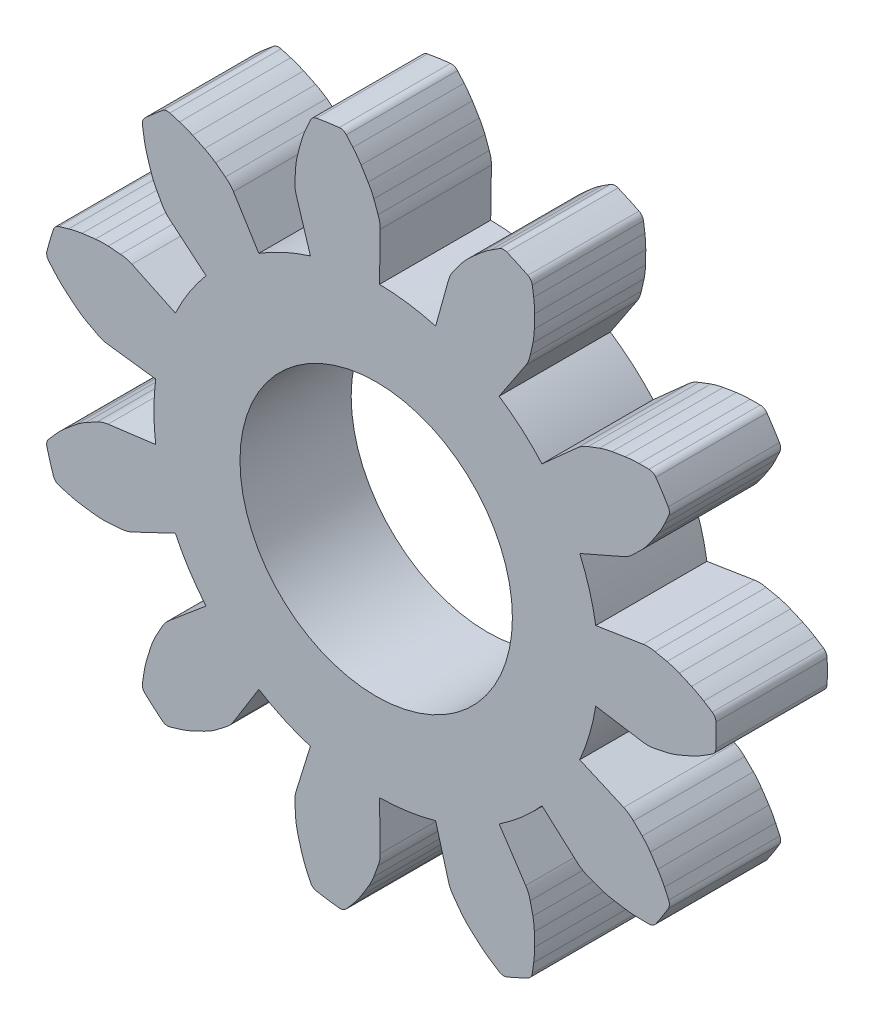
from build123d import *

# Parameters (mm, degrees)
BOSS_EXTRUDE1_DEPTH = 2
SKETCH2_R           = 2.45
CUT_EXTRUDE1_DEPTH  = 2


with BuildPart() as part:
    # Model → Boss-Extrude1 (new body)
    with BuildSketch(Plane.XY):
        with BuildLine():
            Line((12.717474525, 8.359321698), (13.570645119, 8.494996797))
            ThreePointArc((13.570645119, 8.494996797), (13.677360097, 8.501294244), (13.783236646, 8.486532792))
            ThreePointArc((13.783236646, 8.486532792), (13.891944703, 8.463851968), (14.000649175, 8.441153964))
            ThreePointArc((14.000649175, 8.441153964), (14.111872173, 8.409461779), (14.220209346, 8.368989483))
            ThreePointArc((14.220209346, 8.368989483), (14.330605558, 8.321811935), (14.440350312, 8.273138193))
            ThreePointArc((14.440350312, 8.273138193), (14.552066881, 8.217929414), (14.659736482, 8.155192999))
            ThreePointArc((14.659736482, 8.155192999), (14.736291079, 8.106775511), (14.812576461, 8.057934955))
            ThreePointArc((14.812576461, 8.057934955), (14.861069615, 8.006646229), (14.880241201, 7.938715604))
            ThreePointArc((14.880241201, 7.938715604), (14.882877492, 7.83507664), (14.88375634, 7.731407877))
            ThreePointArc((14.88375634, 7.731407877), (14.882877492, 7.627739113), (14.880241201, 7.524100149))
            ThreePointArc((14.880241201, 7.524100149), (14.861069615, 7.456169524), (14.812576461, 7.404880798))
            ThreePointArc((14.812576461, 7.404880798), (14.736291079, 7.356040242), (14.659736482, 7.307622754))
            ThreePointArc((14.659736482, 7.307622754), (14.552066881, 7.244886339), (14.440350312, 7.18967756))
            ThreePointArc((14.440350312, 7.18967756), (14.330605558, 7.141003818), (14.220209346, 7.09382627))
            ThreePointArc((14.220209346, 7.09382627), (14.111872173, 7.053353974), (14.000649175, 7.021661789))
            ThreePointArc((14.000649175, 7.021661789), (13.891944703, 6.998963785), (13.783236646, 6.976282961))
            ThreePointArc((13.783236646, 6.976282961), (13.677360097, 6.961521509), (13.570645119, 6.967818956))
            Line((13.570645119, 6.967818956), (12.717474525, 7.103494055))
            ThreePointArc((12.717474525, 7.103494055), (12.669277659, 6.852450167), (12.605136581, 6.604999376))
            ThreePointArc((12.605136581, 6.604999376), (12.525313492, 6.362153239), (12.430134702, 6.124904488))
            Line((12.430134702, 6.124904488), (13.221218975, 5.777782798))
            ThreePointArc((13.221218975, 5.777782798), (13.314397984, 5.725386074), (13.395486362, 5.655726766))
            ThreePointArc((13.395486362, 5.655726766), (13.47467522, 5.57787443), (13.553851773, 5.50000958))
            ThreePointArc((13.553851773, 5.50000958), (13.630284425, 5.413216725), (13.699542479, 5.320597764))
            ThreePointArc((13.699542479, 5.320597764), (13.766907574, 5.221224788), (13.832915725, 5.120945336))
            ThreePointArc((13.832915725, 5.120945336), (13.897049563, 5.014102219), (13.953709129, 4.903114407))
            ThreePointArc((13.953709129, 4.903114407), (13.991934483, 4.820994484), (14.029704632, 4.738664203))
            ThreePointArc((14.029704632, 4.738664203), (14.042770891, 4.669300002), (14.022172987, 4.601788183))
            ThreePointArc((14.022172987, 4.601788183), (13.968359322, 4.513176251), (13.913051091, 4.425489396))
            ThreePointArc((13.913051091, 4.425489396), (13.856264192, 4.338752824), (13.798014948, 4.252991466))
            ThreePointArc((13.798014948, 4.252991466), (13.745160716, 4.20620953), (13.676636899, 4.189280087))
            ThreePointArc((13.676636899, 4.189280087), (13.586056354, 4.189435788), (13.495478059, 4.190092944))
            ThreePointArc((13.495478059, 4.190092944), (13.370982759, 4.195526295), (13.247152683, 4.209480251))
            ThreePointArc((13.247152683, 4.209480251), (13.128514508, 4.227865787), (13.010137197, 4.247862207))
            ThreePointArc((13.010137197, 4.247862207), (12.897117192, 4.272386242), (12.786416363, 4.305856772))
            ThreePointArc((12.786416363, 4.305856772), (12.682696876, 4.345532071), (12.578983659, 4.38522376))
            ThreePointArc((12.578983659, 4.38522376), (12.481933994, 4.430046821), (12.395564299, 4.493039043))
            Line((12.395564299, 4.493039043), (11.751183019, 5.068435048))
            ThreePointArc((11.751183019, 5.068435048), (11.574912663, 4.883300682), (11.387171756, 4.709809115))
            ThreePointArc((11.387171756, 4.709809115), (11.188727766, 4.548669565), (10.980391915, 4.400540754))
            Line((10.980391915, 4.400540754), (11.4582262, 3.680830957))
            ThreePointArc((11.4582262, 3.680830957), (11.508285563, 3.586375653), (11.538840782, 3.483934827))
            ThreePointArc((11.538840782, 3.483934827), (11.563368537, 3.375628545), (11.587879177, 3.267318388))
            ThreePointArc((11.587879177, 3.267318388), (11.605254654, 3.152980981), (11.613444647, 3.037621223))
            ThreePointArc((11.613444647, 3.037621223), (11.616390684, 2.917603035), (11.617705109, 2.797555891))
            ThreePointArc((11.617705109, 2.797555891), (11.613894177, 2.673000371), (11.601554695, 2.548999008))
            ThreePointArc((11.601554695, 2.548999008), (11.589314528, 2.459249146), (11.576577688, 2.369568422))
            ThreePointArc((11.576577688, 2.369568422), (11.550068607, 2.30415139), (11.496240902, 2.258492901))
            ThreePointArc((11.496240902, 2.258492901), (11.403062739, 2.213041664), (11.309127401, 2.169176675))
            ThreePointArc((11.309127401, 2.169176675), (11.21446189, 2.126910543), (11.119093417, 2.086255416))
            ThreePointArc((11.119093417, 2.086255416), (11.049337383, 2.075475102), (10.982538733, 2.098279921))
            ThreePointArc((10.982538733, 2.098279921), (10.906421707, 2.147382445), (10.830577682, 2.196905604))
            ThreePointArc((10.830577682, 2.196905604), (10.728783063, 2.268783669), (10.632154652, 2.347470079))
            ThreePointArc((10.632154652, 2.347470079), (10.542289839, 2.427077616), (10.453515389, 2.50789928))
            ThreePointArc((10.453515389, 2.50789928), (10.371695605, 2.589633439), (10.296663677, 2.677640028))
            ThreePointArc((10.296663677, 2.677640028), (10.230859377, 2.767092002), (10.165069214, 2.856554373))
            ThreePointArc((10.165069214, 2.856554373), (10.107659017, 2.946730942), (10.069056373, 3.046418354))
            Line((10.069056373, 3.046418354), (9.838050911, 3.878851097))
            ThreePointArc((9.838050911, 3.878851097), (9.589671656, 3.818405108), (9.337937332, 3.773955112))
            ThreePointArc((9.337937332, 3.773955112), (9.083877007, 3.745682816), (8.828529254, 3.733703796))
            Line((8.828529254, 3.733703796), (8.841404541, 2.869908668))
            ThreePointArc((8.841404541, 2.869908668), (8.832450765, 2.763383675), (8.802771759, 2.660685569))
            ThreePointArc((8.802771759, 2.660685569), (8.764851023, 2.556311822), (8.726913793, 2.451944068))
            ThreePointArc((8.726913793, 2.451944068), (8.679715506, 2.346363427), (8.624237172, 2.244888779))
            ThreePointArc((8.624237172, 2.244888779), (8.561828805, 2.142330307), (8.498032184, 2.040629591))
            ThreePointArc((8.498032184, 2.040629591), (8.427486425, 1.937907165), (8.350065594, 1.840261808))
            ThreePointArc((8.350065594, 1.840261808), (8.291246072, 1.771376953), (8.2320461, 1.702818782))
            ThreePointArc((8.2320461, 1.702818782), (8.174378124, 1.662118365), (8.104410534, 1.652809454))
            ThreePointArc((8.104410534, 1.652809454), (8.001451282, 1.664949359), (7.898712644, 1.67883306))
            ThreePointArc((7.898712644, 1.67883306), (7.796224152, 1.694456566), (7.694015266, 1.711815386))
            ThreePointArc((7.694015266, 1.711815386), (7.629504479, 1.740459368), (7.585639093, 1.795758079))
            ThreePointArc((7.585639093, 1.795758079), (7.548152206, 1.878217722), (7.511122393, 1.96088363))
            ThreePointArc((7.511122393, 1.96088363), (7.464347526, 2.076385633), (7.425599618, 2.194822116))
            ThreePointArc((7.425599618, 2.194822116), (7.393039611, 2.310376823), (7.362053282, 2.426363425))
            ThreePointArc((7.362053282, 2.426363425), (7.337410922, 2.53935769), (7.321870001, 2.653958867))
            ThreePointArc((7.321870001, 2.653958867), (7.31487329, 2.764787146), (7.307894093, 2.87561653))
            ThreePointArc((7.307894093, 2.87561653), (7.308350696, 2.982516183), (7.329771168, 3.087248736))
            Line((7.329771168, 3.087248736), (7.585484126, 3.912426704))
            ThreePointArc((7.585484126, 3.912426704), (7.343854632, 3.995860265), (7.10805076, 4.094564399))
            ThreePointArc((7.10805076, 4.094564399), (6.879036457, 4.208135612), (6.65774791, 4.336109637))
            Line((6.65774791, 4.336109637), (6.201576387, 3.602478028))
            ThreePointArc((6.201576387, 3.602478028), (6.136452232, 3.517704279), (6.055961876, 3.447354816))
            ThreePointArc((6.055961876, 3.447354816), (5.967632214, 3.38005153), (5.879291918, 3.312762203))
            ThreePointArc((5.879291918, 3.312762203), (5.782504988, 3.249459437), (5.680972307, 3.194087382))
            ThreePointArc((5.680972307, 3.194087382), (5.573023751, 3.141550216), (5.46437106, 3.090485187))
            ThreePointArc((5.46437106, 3.090485187), (5.349488255, 3.0422095), (5.231566642, 3.001921859))
            ThreePointArc((5.231566642, 3.001921859), (5.144842547, 2.975772467), (5.057975016, 2.950103585))
            ThreePointArc((5.057975016, 2.950103585), (4.987457321, 2.947041876), (4.923564061, 2.977038057))
            ThreePointArc((4.923564061, 2.977038057), (4.843512555, 3.042914769), (4.764589408, 3.110139183))
            ThreePointArc((4.764589408, 3.110139183), (4.686817307, 3.178691975), (4.610218607, 3.248553439))
            ThreePointArc((4.610218607, 3.248553439), (4.571434785, 3.307527455), (4.564429615, 3.377763109))
            ThreePointArc((4.564429615, 3.377763109), (4.577474687, 3.467399516), (4.591015791, 3.556962332))
            ThreePointArc((4.591015791, 3.556962332), (4.614111366, 3.679417202), (4.645546148, 3.800001012))
            ThreePointArc((4.645546148, 3.800001012), (4.680628519, 3.914815087), (4.717268251, 4.0291417))
            ThreePointArc((4.717268251, 4.0291417), (4.757627091, 4.13752119), (4.80651131, 4.242331891))
            ThreePointArc((4.80651131, 4.242331891), (4.860543594, 4.33934928), (4.914591208, 4.43635813))
            ThreePointArc((4.914591208, 4.43635813), (4.972769642, 4.526040982), (5.047412384, 4.60256683))
            Line((5.047412384, 4.60256683), (5.708656704, 5.158501849))
            ThreePointArc((5.708656704, 5.158501849), (5.550492627, 5.359325394), (5.405485271, 5.569845793))
            ThreePointArc((5.405485271, 5.569845793), (5.274227413, 5.789202458), (5.157255622, 6.016498679))
            Line((5.157255622, 6.016498679), (4.376868525, 5.645953442))
            ThreePointArc((4.376868525, 5.645953442), (4.276250449, 5.609846002), (4.170503862, 5.59418064))
            ThreePointArc((4.170503862, 5.59418064), (4.059809318, 5.585316134), (3.949113375, 5.576469119))
            ThreePointArc((3.949113375, 5.576469119), (3.83346697, 5.575542408), (3.71811585, 5.583853184))
            ThreePointArc((3.71811585, 5.583853184), (3.59890001, 5.598017502), (3.479887711, 5.613800946))
            ThreePointArc((3.479887711, 5.613800946), (3.357142338, 5.635299187), (3.236159221, 5.665160304))
            ThreePointArc((3.236159221, 5.665160304), (3.149064841, 5.690048622), (3.062109578, 5.715418716))
            ThreePointArc((3.062109578, 5.715418716), (3.001131033, 5.750967788), (2.963597763, 5.810745485))
            ThreePointArc((2.963597763, 5.810745485), (2.93186979, 5.909443614), (2.901819675, 6.008665464))
            ThreePointArc((2.901819675, 6.008665464), (2.873456058, 6.108382515), (2.846787091, 6.208566102))
            ThreePointArc((2.846787091, 6.208566102), (2.846043824, 6.279146318), (2.878122961, 6.342019591))
            ThreePointArc((2.878122961, 6.342019591), (2.937558274, 6.410373837), (2.997371089, 6.478397999))
            ThreePointArc((2.997371089, 6.478397999), (3.083004425, 6.56892718), (3.174641576, 6.65337381))
            ThreePointArc((3.174641576, 6.65337381), (3.26622792, 6.730994594), (3.358860857, 6.807363327))
            ThreePointArc((3.358860857, 6.807363327), (3.45140725, 6.87671832), (3.549196215, 6.938461888))
            ThreePointArc((3.549196215, 6.938461888), (3.647102625, 6.990866051), (3.745017316, 7.043254742))
            ThreePointArc((3.745017316, 7.043254742), (3.84244634, 7.087247123), (3.946612807, 7.11126985))
            Line((3.946612807, 7.11126985), (4.80344809, 7.221456478))
            ThreePointArc((4.80344809, 7.221456478), (4.778965407, 7.475909951), (4.770793377, 7.731407877))
            ThreePointArc((4.770793377, 7.731407877), (4.778965407, 7.986905802), (4.80344809, 8.241359275))
            Line((4.80344809, 8.241359275), (3.946612807, 8.351545903))
            ThreePointArc((3.946612807, 8.351545903), (3.84244634, 8.37556863), (3.745017316, 8.419561011))
            ThreePointArc((3.745017316, 8.419561011), (3.647102625, 8.471949702), (3.549196215, 8.524353865))
            ThreePointArc((3.549196215, 8.524353865), (3.45140725, 8.586097433), (3.358860857, 8.655452426))
            ThreePointArc((3.358860857, 8.655452426), (3.26622792, 8.731821159), (3.174641576, 8.809441943))
            ThreePointArc((3.174641576, 8.809441943), (3.083004425, 8.893888573), (2.997371089, 8.984417754))
            ThreePointArc((2.997371089, 8.984417754), (2.937558274, 9.052441916), (2.878122961, 9.120796162))
            ThreePointArc((2.878122961, 9.120796162), (2.846043824, 9.183669435), (2.846787091, 9.254249651))
            ThreePointArc((2.846787091, 9.254249651), (2.873456058, 9.354433239), (2.901819675, 9.454150289))
            ThreePointArc((2.901819675, 9.454150289), (2.93186979, 9.553372139), (2.963597763, 9.652070268))
            ThreePointArc((2.963597763, 9.652070268), (3.001131033, 9.711847965), (3.062109578, 9.747397037))
            ThreePointArc((3.062109578, 9.747397037), (3.149064841, 9.772767131), (3.236159221, 9.797655449))
            ThreePointArc((3.236159221, 9.797655449), (3.357142338, 9.827516566), (3.479887711, 9.849014807))
            ThreePointArc((3.479887711, 9.849014807), (3.59890001, 9.864798251), (3.71811585, 9.878962569))
            ThreePointArc((3.71811585, 9.878962569), (3.83346697, 9.887273345), (3.949113375, 9.886346634))
            ThreePointArc((3.949113375, 9.886346634), (4.059809318, 9.87749962), (4.170503862, 9.868635113))
            ThreePointArc((4.170503862, 9.868635113), (4.276250449, 9.852969751), (4.376868525, 9.816862311))
            Line((4.376868525, 9.816862311), (5.157255622, 9.446317074))
            ThreePointArc((5.157255622, 9.446317074), (5.274227413, 9.673613295), (5.405485271, 9.89296996))
            ThreePointArc((5.405485271, 9.89296996), (5.550492627, 10.103490359), (5.708656704, 10.304313904))
            Line((5.708656704, 10.304313904), (5.047412384, 10.860248923))
            ThreePointArc((5.047412384, 10.860248923), (4.972769642, 10.936774771), (4.914591208, 11.026457624))
            ThreePointArc((4.914591208, 11.026457624), (4.860543594, 11.123466473), (4.80651131, 11.220483862))
            ThreePointArc((4.80651131, 11.220483862), (4.757627091, 11.325294563), (4.717268251, 11.433674053))
            ThreePointArc((4.717268251, 11.433674053), (4.680628519, 11.548000666), (4.645546148, 11.662814741))
            ThreePointArc((4.645546148, 11.662814741), (4.614111366, 11.783398551), (4.591015791, 11.905853421))
            ThreePointArc((4.591015791, 11.905853421), (4.577474687, 11.995416237), (4.564429615, 12.085052644))
            ThreePointArc((4.564429615, 12.085052644), (4.571434785, 12.155288298), (4.610218607, 12.214262314))
            ThreePointArc((4.610218607, 12.214262314), (4.686817307, 12.284123778), (4.764589408, 12.35267657))
            ThreePointArc((4.764589408, 12.35267657), (4.843512555, 12.419900984), (4.923564061, 12.485777696))
            ThreePointArc((4.923564061, 12.485777696), (4.987457321, 12.515773877), (5.057975016, 12.512712169))
            ThreePointArc((5.057975016, 12.512712169), (5.144842547, 12.487043286), (5.231566642, 12.460893894))
            ThreePointArc((5.231566642, 12.460893894), (5.349488255, 12.420606253), (5.46437106, 12.372330566))
            ThreePointArc((5.46437106, 12.372330566), (5.573023751, 12.321265537), (5.680972307, 12.268728371))
            ThreePointArc((5.680972307, 12.268728371), (5.782504988, 12.213356316), (5.879291918, 12.15005355))
            ThreePointArc((5.879291918, 12.15005355), (5.967632214, 12.082764223), (6.055961876, 12.015460937))
            ThreePointArc((6.055961876, 12.015460937), (6.136452232, 11.945111474), (6.201576387, 11.860337725))
            Line((6.201576387, 11.860337725), (6.65774791, 11.126706116))
            ThreePointArc((6.65774791, 11.126706116), (6.879036457, 11.254680141), (7.10805076, 11.368251354))
            ThreePointArc((7.10805076, 11.368251354), (7.343854632, 11.466955488), (7.585484126, 11.550389049))
            Line((7.585484126, 11.550389049), (7.329771168, 12.375567018))
            ThreePointArc((7.329771168, 12.375567018), (7.308350696, 12.48029957), (7.307894093, 12.587199223))
            ThreePointArc((7.307894093, 12.587199223), (7.31487329, 12.698028607), (7.321870001, 12.808856886))
            ThreePointArc((7.321870001, 12.808856886), (7.337410922, 12.923458063), (7.362053282, 13.036452328))
            ThreePointArc((7.362053282, 13.036452328), (7.393039611, 13.15243893), (7.425599618, 13.267993637))
            ThreePointArc((7.425599618, 13.267993637), (7.464347526, 13.38643012), (7.511122393, 13.501932123))
            ThreePointArc((7.511122393, 13.501932123), (7.548152206, 13.584598031), (7.585639093, 13.667057674))
            ThreePointArc((7.585639093, 13.667057674), (7.629504479, 13.722356385), (7.694015266, 13.751000367))
            ThreePointArc((7.694015266, 13.751000367), (7.796224152, 13.768359187), (7.898712644, 13.783982693))
            ThreePointArc((7.898712644, 13.783982693), (8.001451282, 13.797866394), (8.104410534, 13.810006299))
            ThreePointArc((8.104410534, 13.810006299), (8.174378124, 13.800697388), (8.2320461, 13.759996971))
            ThreePointArc((8.2320461, 13.759996971), (8.291246072, 13.6914388), (8.350065594, 13.622553946))
            ThreePointArc((8.350065594, 13.622553946), (8.427486425, 13.524908588), (8.498032184, 13.422186162))
            ThreePointArc((8.498032184, 13.422186162), (8.561828805, 13.320485446), (8.624237172, 13.217926975))
            ThreePointArc((8.624237172, 13.217926975), (8.679715506, 13.116452326), (8.726913793, 13.010871686))
            ThreePointArc((8.726913793, 13.010871686), (8.764851023, 12.906503932), (8.802771759, 12.802130184))
            ThreePointArc((8.802771759, 12.802130184), (8.832450765, 12.699432078), (8.841404541, 12.592907085))
            Line((8.841404541, 12.592907085), (8.828529254, 11.729111957))
            ThreePointArc((8.828529254, 11.729111957), (9.083877007, 11.717132937), (9.337937332, 11.688860641))
            ThreePointArc((9.337937332, 11.688860641), (9.589671656, 11.644410645), (9.838050911, 11.583964656))
            Line((9.838050911, 11.583964656), (10.069056373, 12.416397399))
            ThreePointArc((10.069056373, 12.416397399), (10.107659017, 12.516084811), (10.165069214, 12.60626138))
            ThreePointArc((10.165069214, 12.60626138), (10.230859377, 12.695723751), (10.296663677, 12.785175725))
            ThreePointArc((10.296663677, 12.785175725), (10.371695605, 12.873182314), (10.453515389, 12.954916473))
            ThreePointArc((10.453515389, 12.954916473), (10.542289839, 13.035738137), (10.632154652, 13.115345674))
            ThreePointArc((10.632154652, 13.115345674), (10.728783063, 13.194032084), (10.830577682, 13.265910149))
            ThreePointArc((10.830577682, 13.265910149), (10.906421707, 13.315433308), (10.982538733, 13.364535832))
            ThreePointArc((10.982538733, 13.364535832), (11.049337383, 13.387340651), (11.119093417, 13.376560337))
            ThreePointArc((11.119093417, 13.376560337), (11.21446189, 13.33590521), (11.309127401, 13.293639078))
            ThreePointArc((11.309127401, 13.293639078), (11.403062739, 13.249774089), (11.496240902, 13.204322852))
            ThreePointArc((11.496240902, 13.204322852), (11.550068607, 13.158664363), (11.576577688, 13.093247332))
            ThreePointArc((11.576577688, 13.093247332), (11.589314528, 13.003566607), (11.601554695, 12.913816745))
            ThreePointArc((11.601554695, 12.913816745), (11.613894177, 12.789815382), (11.617705109, 12.665259862))
            ThreePointArc((11.617705109, 12.665259862), (11.616390684, 12.545212718), (11.613444647, 12.425194531))
            ThreePointArc((11.613444647, 12.425194531), (11.605254654, 12.309834772), (11.587879177, 12.195497365))
            ThreePointArc((11.587879177, 12.195497365), (11.563368537, 12.087187208), (11.538840782, 11.978880926))
            ThreePointArc((11.538840782, 11.978880926), (11.508285563, 11.8764401), (11.4582262, 11.781984796))
            Line((11.4582262, 11.781984796), (10.980391915, 11.062274999))
            ThreePointArc((10.980391915, 11.062274999), (11.188727766, 10.914146188), (11.387171756, 10.753006638))
            ThreePointArc((11.387171756, 10.753006638), (11.574912663, 10.579515071), (11.751183019, 10.394380705))
            Line((11.751183019, 10.394380705), (12.395564299, 10.96977671))
            ThreePointArc((12.395564299, 10.96977671), (12.481933994, 11.032768932), (12.578983659, 11.077591993))
            ThreePointArc((12.578983659, 11.077591993), (12.682696876, 11.117283682), (12.786416363, 11.156958981))
            ThreePointArc((12.786416363, 11.156958981), (12.897117192, 11.190429511), (13.010137197, 11.214953546))
            ThreePointArc((13.010137197, 11.214953546), (13.128514508, 11.234949966), (13.247152683, 11.253335502))
            ThreePointArc((13.247152683, 11.253335502), (13.370982759, 11.267289458), (13.495478059, 11.272722809))
            ThreePointArc((13.495478059, 11.272722809), (13.586056354, 11.273379965), (13.676636899, 11.273535666))
            ThreePointArc((13.676636899, 11.273535666), (13.745160716, 11.256606223), (13.798014948, 11.209824287))
            ThreePointArc((13.798014948, 11.209824287), (13.856264192, 11.124062929), (13.913051091, 11.037326357))
            ThreePointArc((13.913051091, 11.037326357), (13.968359322, 10.949639502), (14.022172987, 10.86102757))
            ThreePointArc((14.022172987, 10.86102757), (14.042770891, 10.793515751), (14.029704632, 10.72415155))
            ThreePointArc((14.029704632, 10.72415155), (13.991934483, 10.641821269), (13.953709129, 10.559701346))
            ThreePointArc((13.953709129, 10.559701346), (13.897049563, 10.448713534), (13.832915725, 10.341870417))
            ThreePointArc((13.832915725, 10.341870417), (13.766907574, 10.241590965), (13.699542479, 10.142217989))
            ThreePointArc((13.699542479, 10.142217989), (13.630284425, 10.049599028), (13.553851773, 9.962806173))
            ThreePointArc((13.553851773, 9.962806173), (13.47467522, 9.884941323), (13.395486362, 9.807088987))
            ThreePointArc((13.395486362, 9.807088987), (13.314397984, 9.737429679), (13.221218975, 9.685032956))
            Line((13.221218975, 9.685032956), (12.430134702, 9.337911265))
            ThreePointArc((12.430134702, 9.337911265), (12.525313492, 9.100662514), (12.605136581, 8.857816377))
            ThreePointArc((12.605136581, 8.857816377), (12.669277659, 8.610365586), (12.717474525, 8.359321698))
        make_face()
    extrude(amount=BOSS_EXTRUDE1_DEPTH)

    # Sketch2 → Cut-Extrude1 (cut)
    with BuildSketch(Plane.XY.offset(2)):
        with Locations((8.768941525, 7.731407877)):
            Circle(SKETCH2_R)
    extrude(amount=-CUT_EXTRUDE1_DEPTH, mode=Mode.SUBTRACT)


solid = part.part
